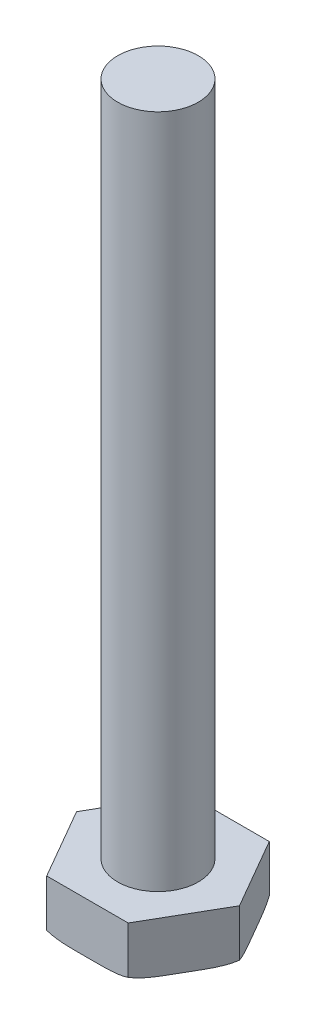
from build123d import *

# Parameters (mm, degrees)
BOSS_EXTRUDE1_DEPTH = 3.96875
SKETCH3_R           = 3.175
BOSS_EXTRUDE2_DEPTH = 57.15


with BuildPart() as part:
    # Sketch1 → Boss-Extrude1 (new body)
    with BuildSketch(Plane(origin=(0, 0, 0), x_dir=(1, 0, 0), z_dir=(0, 1, 0))):
        Polygon((6.415804866, 0), (3.207902433, 5.55625), (-3.207902433, 5.55625), (-6.415804866, 0), (-3.207902433, -5.55625), (3.207902433, -5.55625), align=None)
    extrude(amount=BOSS_EXTRUDE1_DEPTH)

    # Sketch2 → Cut-Revolve1 (revolve, cut)
    with BuildSketch(Plane.XY):
        with BuildLine():
            Line((6.415804866, 0.254), (6.415804866, 0))
            Line((6.415804866, 0), (5.592494081, 0))
            ThreePointArc((5.592494081, 0), (6.023294687, 0.064943068), (6.415804866, 0.254))
        make_face()
    revolve(axis=Axis((0, 0, 0), (0, 1, 0)), mode=Mode.SUBTRACT)

    # Sketch3 → Boss-Extrude2 (add)
    with BuildSketch(Plane(origin=(0, 0, 0), x_dir=(1, 0, 0), z_dir=(0, 1, 0))):
        Circle(SKETCH3_R)
    extrude(amount=BOSS_EXTRUDE2_DEPTH)


solid = part.part
